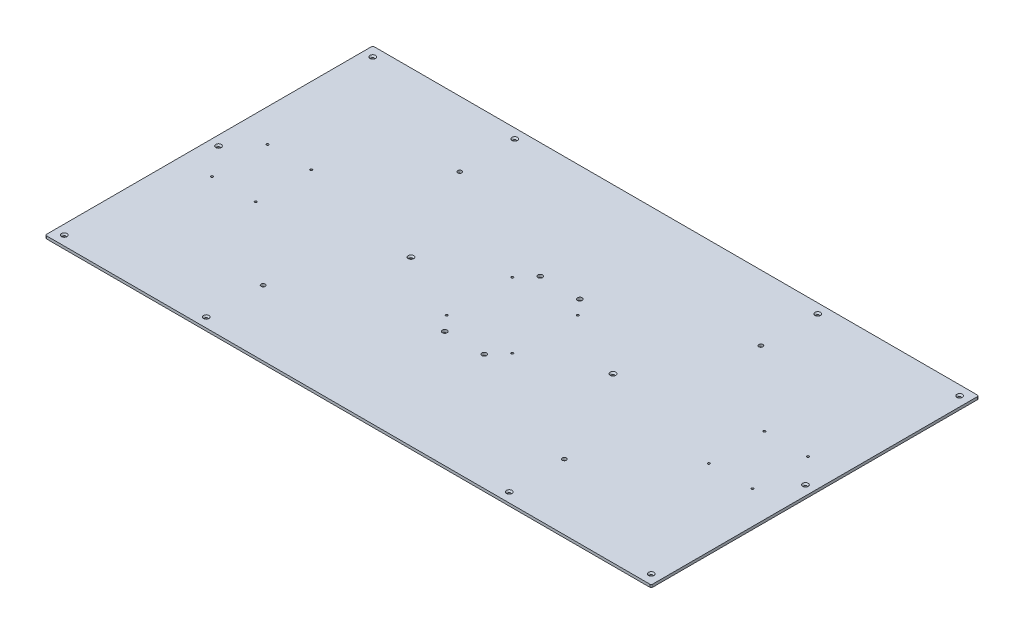
from build123d import *

# Parameters (mm, degrees)
SKETCH1_W                                     = 1409.7
SKETCH1_H                                     = 762
BOSS_EXTRUDE1_DEPTH                           = 6.35
CSK_FOR_1_4_FLAT_HEAD_MACHINE_SCREW1_AT_COUNT = 2
CSK_FOR_1_4_FLAT_HEAD_MACHINE_SCREW1_AT_PITCH = 330.2
CSK_FOR_1_4_FLAT_HEAD_MACHINE_SCREW1_2_COUNT  = 2
CSK_FOR_1_4_FLAT_HEAD_MACHINE_SCREW1_2_PITCH  = 1035.05
CSK_FOR_1_4_FLAT_HEAD_MACHINE_SCREW1_3_COUNT  = 2
CSK_FOR_1_4_FLAT_HEAD_MACHINE_SCREW1_3_PITCH  = 1365.25
CSK_FOR_1_4_FLAT_HEAD_MACHINE_SCREW1_4_COUNT  = 2
CSK_FOR_1_4_FLAT_HEAD_MACHINE_SCREW1_4_PITCH  = 717.55
CSK_FOR_1_4_FLAT_HEAD_MACHINE_SCREW1_5_COUNT  = 2
CSK_FOR_1_4_FLAT_HEAD_MACHINE_SCREW1_5_PITCH  = 573.700624237
CSK_FOR_1_4_FLAT_HEAD_MACHINE_SCREW1_6_COUNT  = 2
CSK_FOR_1_4_FLAT_HEAD_MACHINE_SCREW1_6_PITCH  = 789.879764584
CSK_FOR_1_4_FLAT_HEAD_MACHINE_SCREW1_7_COUNT  = 2
CSK_FOR_1_4_FLAT_HEAD_MACHINE_SCREW1_7_PITCH  = 985.222503422
CSK_FOR_1_4_FLAT_HEAD_MACHINE_SCREW1_8_COUNT  = 2
CSK_FOR_1_4_FLAT_HEAD_MACHINE_SCREW1_8_PITCH  = 1259.446904399
CSK_FOR_1_4_FLAT_HEAD_MACHINE_SCREW1_9_COUNT  = 2
CSK_FOR_1_4_FLAT_HEAD_MACHINE_SCREW1_9_PITCH  = 1542.331211186
CSK_FOR_1_4_FLAT_HEAD_MACHINE_SCREW1_10_COUNT = 2
CSK_FOR_1_4_FLAT_HEAD_MACHINE_SCREW1_10_PITCH = 358.775
CSK_FOR_1_4_FLAT_HEAD_MACHINE_SCREW1_11_COUNT = 2
CSK_FOR_1_4_FLAT_HEAD_MACHINE_SCREW1_11_PITCH = 1411.6044287
F_8_0_199_DIAMETER_HOLE2_D                    = 5.0546
F_7_16_0_4375_DIAMETER_HOLE1_D                = 11.1125
F_8_0_199_DIAMETER_HOLE1_D                    = 5.0546
F_3_8_0_375_DIAMETER_HOLE1_D                  = 9.525
FILLET1_R                                     = 3.175


with BuildPart() as part:
    # Sketch1 → Boss-Extrude1 (new body)
    with BuildSketch(Plane(origin=(0, 0, 0), x_dir=(1, 0, 0), z_dir=(0, 1, 0))):
        with Locations((704.85, 381)):
            Rectangle(SKETCH1_W, SKETCH1_H)
    extrude(amount=BOSS_EXTRUDE1_DEPTH)

    # Sketch5 → CSK for 1/4 Flat Head Machine Screw1 (revolve, cut)
    with BuildSketch(Plane(origin=(1387.475, 6.35, -739.775), x_dir=(0, 0, 1), z_dir=(1, 0, 0))):
        Polygon((0, 0), (0, 6.35), (3.3782, 6.35), (3.3782, 3.520932584), (6.4389, 0), align=None)
    csk_for_1_4_flat_head_machine_screw1 = revolve(axis=Axis((1387.475, 12.7, -739.775), (0, -1, 0)), mode=Mode.SUBTRACT)

    # CSK for 1/4 Flat Head Machine Screw1 at: CSK for 1/4 Flat Head Machine Screw1 ×2
    with Locations(*[(-i * CSK_FOR_1_4_FLAT_HEAD_MACHINE_SCREW1_AT_PITCH, 0, 0) for i in range(1, CSK_FOR_1_4_FLAT_HEAD_MACHINE_SCREW1_AT_COUNT)]):
        add(csk_for_1_4_flat_head_machine_screw1, mode=Mode.SUBTRACT)

    # CSK for 1_4 Flat Head Machine Screw1 2: CSK for 1/4 Flat Head Machine Screw1 ×2
    with Locations(*[(-i * CSK_FOR_1_4_FLAT_HEAD_MACHINE_SCREW1_2_PITCH, 0, 0) for i in range(1, CSK_FOR_1_4_FLAT_HEAD_MACHINE_SCREW1_2_COUNT)]):
        add(csk_for_1_4_flat_head_machine_screw1, mode=Mode.SUBTRACT)

    # CSK for 1_4 Flat Head Machine Screw1 3: CSK for 1/4 Flat Head Machine Screw1 ×2
    with Locations(*[(-i * CSK_FOR_1_4_FLAT_HEAD_MACHINE_SCREW1_3_PITCH, 0, 0) for i in range(1, CSK_FOR_1_4_FLAT_HEAD_MACHINE_SCREW1_3_COUNT)]):
        add(csk_for_1_4_flat_head_machine_screw1, mode=Mode.SUBTRACT)

    # CSK for 1_4 Flat Head Machine Screw1 4: CSK for 1/4 Flat Head Machine Screw1 ×2
    with Locations(*[(0, 0, i * CSK_FOR_1_4_FLAT_HEAD_MACHINE_SCREW1_4_PITCH) for i in range(1, CSK_FOR_1_4_FLAT_HEAD_MACHINE_SCREW1_4_COUNT)]):
        add(csk_for_1_4_flat_head_machine_screw1, mode=Mode.SUBTRACT)

    # CSK for 1_4 Flat Head Machine Screw1 5: CSK for 1/4 Flat Head Machine Screw1 ×2
    with Locations(*[Vector(-0.780328591, 0, 0.625369722) * (i * CSK_FOR_1_4_FLAT_HEAD_MACHINE_SCREW1_5_PITCH) for i in range(1, CSK_FOR_1_4_FLAT_HEAD_MACHINE_SCREW1_5_COUNT)]):
        add(csk_for_1_4_flat_head_machine_screw1, mode=Mode.SUBTRACT)

    # CSK for 1_4 Flat Head Machine Screw1 6: CSK for 1/4 Flat Head Machine Screw1 ×2
    with Locations(*[Vector(-0.418038308, 0, 0.908429399) * (i * CSK_FOR_1_4_FLAT_HEAD_MACHINE_SCREW1_6_PITCH) for i in range(1, CSK_FOR_1_4_FLAT_HEAD_MACHINE_SCREW1_6_COUNT)]):
        add(csk_for_1_4_flat_head_machine_screw1, mode=Mode.SUBTRACT)

    # CSK for 1_4 Flat Head Machine Screw1 7: CSK for 1/4 Flat Head Machine Screw1 ×2
    with Locations(*[Vector(-0.931337842, 0, 0.364156319) * (i * CSK_FOR_1_4_FLAT_HEAD_MACHINE_SCREW1_7_PITCH) for i in range(1, CSK_FOR_1_4_FLAT_HEAD_MACHINE_SCREW1_7_COUNT)]):
        add(csk_for_1_4_flat_head_machine_screw1, mode=Mode.SUBTRACT)

    # CSK for 1_4 Flat Head Machine Screw1 8: CSK for 1/4 Flat Head Machine Screw1 ×2
    with Locations(*[Vector(-0.821829008, 0, 0.56973422) * (i * CSK_FOR_1_4_FLAT_HEAD_MACHINE_SCREW1_8_PITCH) for i in range(1, CSK_FOR_1_4_FLAT_HEAD_MACHINE_SCREW1_8_COUNT)]):
        add(csk_for_1_4_flat_head_machine_screw1, mode=Mode.SUBTRACT)

    # CSK for 1_4 Flat Head Machine Screw1 9: CSK for 1/4 Flat Head Machine Screw1 ×2
    with Locations(*[Vector(-0.885186003, 0, 0.465237295) * (i * CSK_FOR_1_4_FLAT_HEAD_MACHINE_SCREW1_9_PITCH) for i in range(1, CSK_FOR_1_4_FLAT_HEAD_MACHINE_SCREW1_9_COUNT)]):
        add(csk_for_1_4_flat_head_machine_screw1, mode=Mode.SUBTRACT)

    # CSK for 1_4 Flat Head Machine Screw1 10: CSK for 1/4 Flat Head Machine Screw1 ×2
    with Locations(*[(0, 0, i * CSK_FOR_1_4_FLAT_HEAD_MACHINE_SCREW1_10_PITCH) for i in range(1, CSK_FOR_1_4_FLAT_HEAD_MACHINE_SCREW1_10_COUNT)]):
        add(csk_for_1_4_flat_head_machine_screw1, mode=Mode.SUBTRACT)

    # CSK for 1_4 Flat Head Machine Screw1 11: CSK for 1/4 Flat Head Machine Screw1 ×2
    with Locations(*[Vector(-0.967161885, 0, 0.254161146) * (i * CSK_FOR_1_4_FLAT_HEAD_MACHINE_SCREW1_11_PITCH) for i in range(1, CSK_FOR_1_4_FLAT_HEAD_MACHINE_SCREW1_11_COUNT)]):
        add(csk_for_1_4_flat_head_machine_screw1, mode=Mode.SUBTRACT)

    # #8 (0.199) Diameter Hole2 (through all)
    with Locations(Plane(origin=(0, 0, 0), x_dir=(-1, 0, 0), z_dir=(0, -1, 0))):
        with Locations((-628.517822971, 305.307902971), (-628.517822971, 457.972257029), (-781.182177029, 305.307902971), (-781.182177029, 457.972257029)):
            Hole(F_8_0_199_DIAMETER_HOLE2_D / 2)

    # 7/16 (0.4375) Diameter Hole1 (through all)
    with Locations(Plane(origin=(0, 6.35, 0), x_dir=(1, 0, 0), z_dir=(0, 1, 0))):
        with Locations((658.829906352, 492.742414226), (750.870093648, 270.537745774), (658.829906352, 270.537745774), (750.870093648, 492.742414226)):
            Hole(F_7_16_0_4375_DIAMETER_HOLE1_D / 2)

    # #8 (0.199) Diameter Hole1 (through all)
    with Locations(Plane(origin=(0, 6.35, 0), x_dir=(1, 0, 0), z_dir=(0, 1, 0))):
        with Locations((1333.5, 311.68467), (1231.9, 311.68467), (1231.9, 441.06592), (1333.5, 441.06592), (76.2, 441.06592), (177.8, 441.06592), (177.8, 311.68467), (76.2, 311.68467)):
            Hole(F_8_0_199_DIAMETER_HOLE1_D / 2)

    # 3/8 (0.375) Diameter Hole1 (through all)
    with Locations(Plane(origin=(0, 6.35, 0), x_dir=(1, 0, 0), z_dir=(0, 1, 0))):
        with Locations((354.532774062, 152.4), (354.532774062, 609.6), (1055.167225938, 609.6), (1055.167225938, 152.4)):
            Hole(F_3_8_0_375_DIAMETER_HOLE1_D / 2)

    # Fillet1
    fillet1_edges = [part.edges().sort_by_distance(p)[0] for p in [
        (0, 3.175, -762),
        (1409.7, 3.175, -762),
        (1409.7, 3.175, 0),
        (0, 3.175, 0),
    ]]
    fillet(fillet1_edges, radius=FILLET1_R)


solid = part.part
